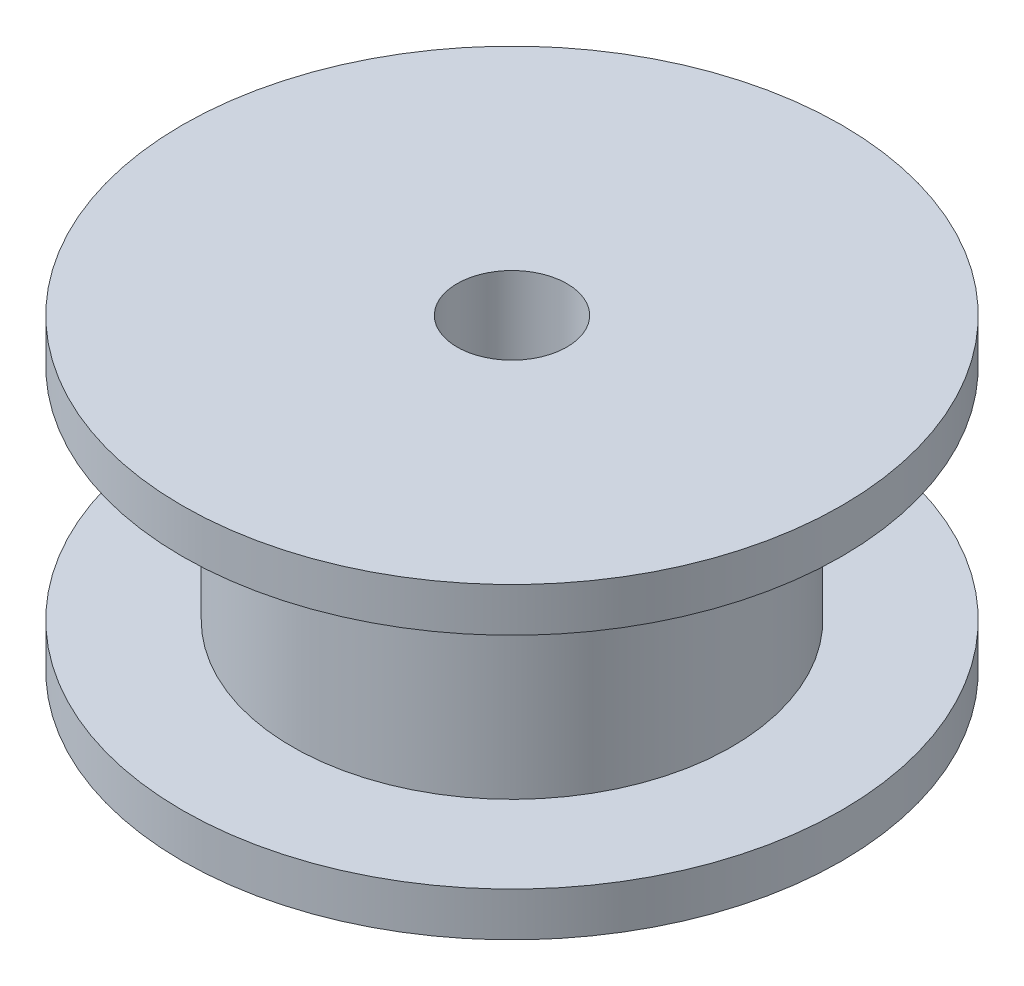
from build123d import *


with BuildPart() as part:
    # Sketch1 → Revolve1 (revolve)
    with BuildSketch(Plane(origin=(0, 0, 0), x_dir=(0, 0, -1), z_dir=(1, 0, 0))):
        Polygon((-3, 2.8), (-0.5, 2.8), (-0.5, 0), (-3, 0), (-3, 0.4), (-2, 0.4), (-2, 2.4), (-3, 2.4), align=None)
    revolve(axis=Axis((0, 0, 0), (0, 1, 0)))


solid = part.part
